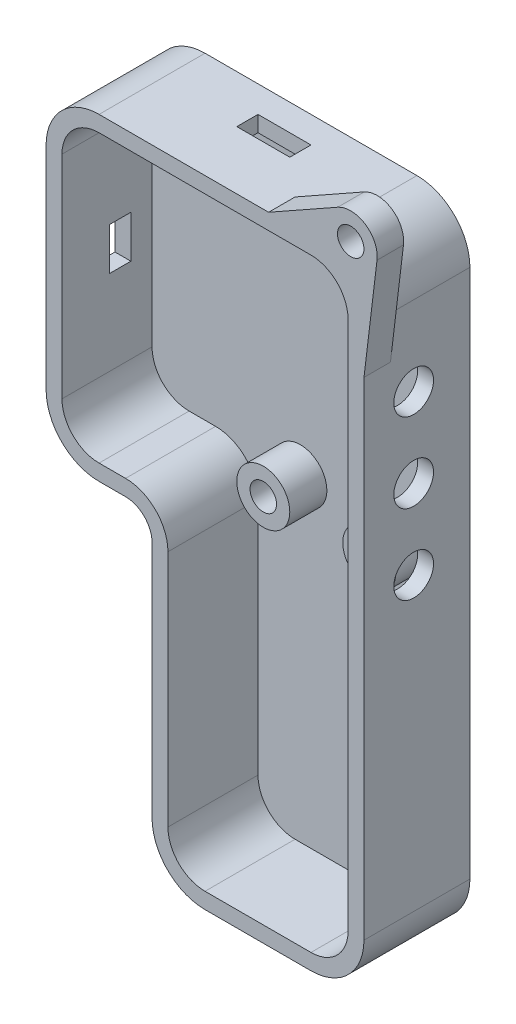
from build123d import *

# Parameters (mm, degrees)
SALIENTE_EXTRUIR1_DEPTH      = 50
SALIENTE_EXTRUIR2_DEPTH      = 60
SALIENTE_EXTRUIR2_DEPTH_BACK = 31
CROQUIS2_W                   = 40
CROQUIS2_H                   = 50
REDONDEO1_R                  = 10
REDONDEO2_R                  = 10
CORTAR_EXTRUIR2_DEPTH        = 76
REDONDEO6_R                  = 5
VACIADO2_T                   = -3
CROQUIS4_R                   = 5
SALIENTE_EXTRUIR3_DEPTH      = 7
CROQUIS5_R                   = 2.5
CORTAR_EXTRUIR3_DEPTH        = 113.43981765
SALIENTE_EXTRUIR4_START      = -5
SALIENTE_EXTRUIR4_DEPTH      = 5
CROQUIS6_4_R                 = 2.5
CORTAR_EXTRUIR4_DEPTH        = 114.766043234
CORTAR_EXTRUIR7_REACH        = 93.286
CROQUIS8_R                   = 3.75
CORTAR_EXTRUIR8_REACH        = 94.948
CROQUIS9_W                   = 4
CROQUIS9_H                   = 8
CORTAR_EXTRUIR9_REACH        = 153.689
CROQUIS10_W                  = 10
CROQUIS10_H                  = 4


with BuildPart() as part:
    # Croquis1 → Saliente-Extruir1 (new body)
    with BuildSketch(Plane.XY):
        with BuildLine():
            Line((-80.606796451, 54.173553719), (-40.606796451, 54.173553719))
            ThreePointArc((-40.606796451, 54.173553719), (-33.53572864, 51.244621531), (-30.606796451, 44.173553719))
            Line((-30.606796451, 44.173553719), (-30.606796451, 4.173553719))
            ThreePointArc((-30.606796451, 4.173553719), (-33.53572864, -2.897514093), (-40.606796451, -5.826446281))
            Line((-40.606796451, -5.826446281), (-80.606796451, -5.826446281))
            ThreePointArc((-80.606796451, -5.826446281), (-87.677864263, -2.897514093), (-90.606796451, 4.173553719))
            Line((-90.606796451, 4.173553719), (-90.606796451, 44.173553719))
            ThreePointArc((-90.606796451, 44.173553719), (-87.677864263, 51.244621531), (-80.606796451, 54.173553719))
        make_face()
    extrude(amount=SALIENTE_EXTRUIR1_DEPTH)

    # Croquis2 → Saliente-Extruir2 (add, two sides: drawn at the far end of the back side and taken through both)
    with BuildSketch(Plane.XZ.offset(5.826446281).offset(-SALIENTE_EXTRUIR2_DEPTH_BACK)):
        with Locations((-50.606796451, 25)):
            Rectangle(CROQUIS2_W, CROQUIS2_H)
    extrude(amount=SALIENTE_EXTRUIR2_DEPTH + SALIENTE_EXTRUIR2_DEPTH_BACK)

    # Redondeo1
    redondeo1_edges = [part.edges().sort_by_distance(p)[0] for p in [
        (-30.606796451, -65.826446281, 25),
    ]]
    fillet(redondeo1_edges, radius=REDONDEO1_R)

    # Redondeo2
    redondeo2_edges = [part.edges().sort_by_distance(p)[0] for p in [
        (-70.606796451, -65.826446281, 25),
    ]]
    fillet(redondeo2_edges, radius=REDONDEO2_R)

    # Croquis3 → Cortar-Extruir2 (cut)
    with BuildSketch(Plane(origin=(-30.606796451, 0, 0), x_dir=(0, 0, -1), z_dir=(1, 0, 0))):
        Polygon((-20, -55.826446281), (-20, 57.222275959), (-50, 57.222275959), (-50, -55.826446281), (-50, -71.304791729), (-20, -71.304791729), align=None)
    extrude(amount=-CORTAR_EXTRUIR2_DEPTH, mode=Mode.SUBTRACT)

    # Redondeo6
    redondeo6_edges = [part.edges().sort_by_distance(p)[0] for p in [
        (-70.606796451, -5.826446281, 10),
    ]]
    fillet(redondeo6_edges, radius=REDONDEO6_R)

    # Vaciado2
    vaciado2_openings = [part.faces().sort_by_distance(p)[0] for p in [
        (-56.519519035, 0.268108162, 20),
    ]]
    offset(amount=VACIADO2_T, openings=vaciado2_openings, kind=Kind.INTERSECTION)

    # Croquis4 → Saliente-Extruir3 (add)
    with BuildSketch(Plane.XY.offset(3)):
        with Locations((-39.606796451, -2.826446281)):
            Circle(CROQUIS4_R)
        with Locations((-59.606796451, -2.826446281)):
            Circle(CROQUIS4_R)
    extrude(amount=SALIENTE_EXTRUIR3_DEPTH)

    # Croquis5 → Cortar-Extruir3 (cut, through all)
    with BuildSketch(Plane.XY.offset(10)):
        with Locations((-59.606796451, -2.826446281)):
            Circle(CROQUIS5_R)
        with Locations((-39.606796451, -2.826446281)):
            Circle(CROQUIS5_R)
    extrude(amount=-CORTAR_EXTRUIR3_DEPTH, mode=Mode.SUBTRACT)

    # Croquis6 → Saliente-Extruir4 (add)
    with BuildSketch(Plane.XY.offset(20).offset(SALIENTE_EXTRUIR4_START)):
        with BuildLine():
            Line((-35.560225021, 61.520617947), (-48.606796451, 54.173553719))
            Line((-48.606796451, 54.173553719), (-40.606796451, 54.173553719))
            ThreePointArc((-40.606796451, 54.173553719), (-33.53572864, 51.244621531), (-30.606796451, 44.173553719))
            Line((-30.606796451, 44.173553719), (-30.606796451, 36.173553719))
            Line((-30.606796451, 36.173553719), (-28.142904197, 56.564123399))
            ThreePointArc((-28.142904197, 56.564123399), (-30.328790596, 61.321179473), (-35.560225021, 61.520617947))
        make_face()
    extrude(amount=SALIENTE_EXTRUIR4_DEPTH)

    # Croquis6_4 → Cortar-Extruir4 (cut, through all)
    with BuildSketch(Plane.XY.offset(20)):
        with Locations((-33.106796451, 57.163934776)):
            Circle(CROQUIS6_4_R)
    extrude(amount=-CORTAR_EXTRUIR4_DEPTH, mode=Mode.SUBTRACT)

    # Croquis8 → Cortar-Extruir7 (cut, up to next)
    with BuildSketch(Plane(origin=(-30.606796451, 0, 0), x_dir=(0, 0, -1), z_dir=(1, 0, 0)), mode=Mode.PRIVATE) as cortar_extruir7_sk1:
        with Locations((-10.615433885, 29.173553719)):
            Circle(CROQUIS8_R)
    cortar_extruir7_tool1 = extrude(cortar_extruir7_sk1.sketch, amount=-CORTAR_EXTRUIR7_REACH, mode=Mode.PRIVATE) & part.part
    # Croquis8 → Cortar-Extruir7 (cut, up to next)
    with BuildSketch(Plane(origin=(-30.606796451, 0, 0), x_dir=(0, 0, -1), z_dir=(1, 0, 0)), mode=Mode.PRIVATE) as cortar_extruir7_sk2:
        with Locations((-10.615433885, 14.173553719)):
            Circle(CROQUIS8_R)
    cortar_extruir7_tool2 = extrude(cortar_extruir7_sk2.sketch, amount=-CORTAR_EXTRUIR7_REACH, mode=Mode.PRIVATE) & part.part
    # Croquis8 → Cortar-Extruir7 (cut, up to next)
    with BuildSketch(Plane(origin=(-30.606796451, 0, 0), x_dir=(0, 0, -1), z_dir=(1, 0, 0)), mode=Mode.PRIVATE) as cortar_extruir7_sk3:
        with Locations((-10.615433885, -0.826446281)):
            Circle(CROQUIS8_R)
    cortar_extruir7_tool3 = extrude(cortar_extruir7_sk3.sketch, amount=-CORTAR_EXTRUIR7_REACH, mode=Mode.PRIVATE) & part.part
    add(cortar_extruir7_tool1.solids().sort_by_distance((-30.606796, 29.173554, 10.615434))[0], mode=Mode.SUBTRACT)
    add(cortar_extruir7_tool2.solids().sort_by_distance((-30.606796, 14.173554, 10.615434))[0], mode=Mode.SUBTRACT)
    add(cortar_extruir7_tool3.solids().sort_by_distance((-30.606796, -0.826446, 10.615434))[0], mode=Mode.SUBTRACT)

    # Croquis9 → Cortar-Extruir8 (cut, up to next)
    with BuildSketch(Plane.ZY.offset(90.606796451), mode=Mode.PRIVATE) as cortar_extruir8_sk1:
        with Locations((9, 24.173553719)):
            Rectangle(CROQUIS9_W, CROQUIS9_H)
    cortar_extruir8_tool1 = extrude(cortar_extruir8_sk1.sketch, amount=-CORTAR_EXTRUIR8_REACH, mode=Mode.PRIVATE) & part.part
    add(cortar_extruir8_tool1.solids().sort_by_distance((-90.606796, 24.173554, 9))[0], mode=Mode.SUBTRACT)

    # Croquis10 → Cortar-Extruir9 (cut, up to next)
    with BuildSketch(Plane(origin=(0, 54.173553719, 0), x_dir=(1, 0, 0), z_dir=(0, 1, 0)), mode=Mode.PRIVATE) as cortar_extruir9_sk1:
        with Locations((-60.606796451, -7)):
            Rectangle(CROQUIS10_W, CROQUIS10_H)
    cortar_extruir9_tool1 = extrude(cortar_extruir9_sk1.sketch, amount=-CORTAR_EXTRUIR9_REACH, mode=Mode.PRIVATE) & part.part
    add(cortar_extruir9_tool1.solids().sort_by_distance((-60.606796, 54.173554, 7))[0], mode=Mode.SUBTRACT)


solid = part.part
